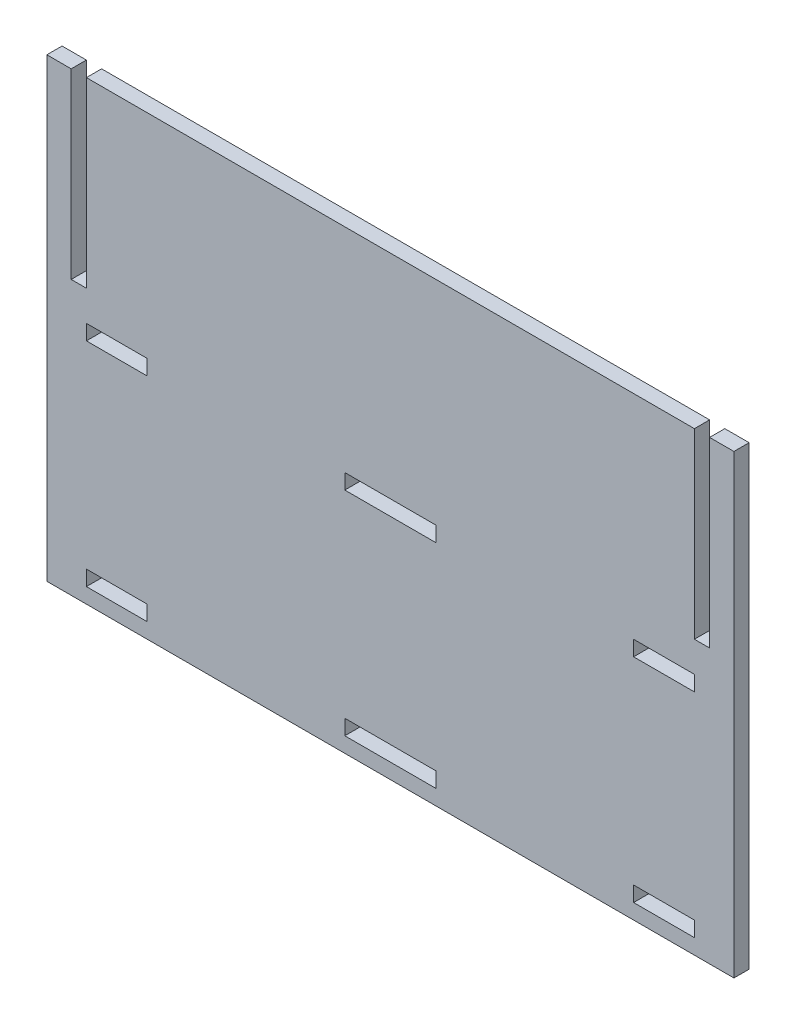
from build123d import *

# Parameters (mm, degrees)
ESQUISSE1_W        = 20
ESQUISSE1_H        = 5
BOSS_EXTRU_1_DEPTH = 5


with BuildPart() as part:
    # Esquisse1 → Boss.-Extru.1 (new body)
    with BuildSketch(Plane.XY):
        Polygon((-100, 150), (100, 150), (100, 90), (105, 90), (105, 150), (113, 150), (113, 0), (-113, 0), (-113, 150), (-105, 150), (-105, 90), (-100, 90), align=None)
        with Locations((90, 7.5)):
            Rectangle(ESQUISSE1_W, ESQUISSE1_H, mode=Mode.SUBTRACT)
        with Locations((90, 77.5)):
            Rectangle(ESQUISSE1_W, ESQUISSE1_H, mode=Mode.SUBTRACT)
        Polygon((-15, 5), (15, 5), (15, 10), (0, 10), (-15, 10), align=None, mode=Mode.SUBTRACT)
        Polygon((-15, 80), (0, 80), (15, 80), (15, 75), (-15, 75), align=None, mode=Mode.SUBTRACT)
        with Locations((-90, 7.5)):
            Rectangle(ESQUISSE1_W, ESQUISSE1_H, mode=Mode.SUBTRACT)
        with Locations((-90, 77.5)):
            Rectangle(ESQUISSE1_W, ESQUISSE1_H, mode=Mode.SUBTRACT)
    extrude(amount=BOSS_EXTRU_1_DEPTH)


solid = part.part
